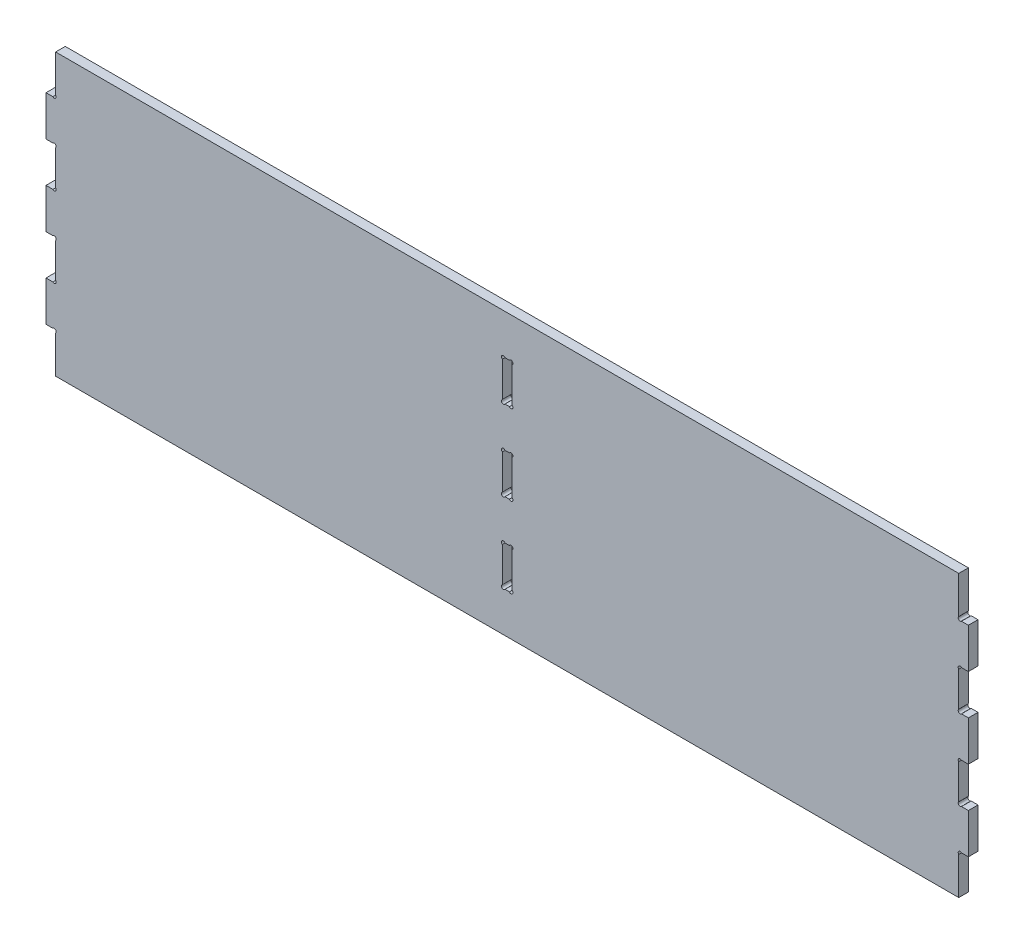
from build123d import *

# Parameters (mm, degrees)
BOSS_EXTRUDE1_DEPTH = 12


with BuildPart() as part:
    # Sketch1 → Boss-Extrude1 (new body)
    with BuildSketch(Plane.XY):
        with BuildLine():
            Line((511.8067094, 188.903885219), (511.8067094, 142.299329353))
            ThreePointArc((511.8067094, 142.299329353), (511.806507744, 138.903885219), (515.20195099, 138.906348311))
            Line((515.20195099, 138.906348311), (523.8067094, 138.906348311))
            Line((523.8067094, 138.906348311), (523.8067094, 138.319810176))
            Line((523.8067094, 138.319810176), (523.8067094, 88.903885219))
            Line((523.8067094, 88.903885219), (518.8067094, 88.903885219))
            Line((518.8067094, 88.903885219), (515.20195099, 88.903885219))
            ThreePointArc((515.20195099, 88.903885219), (511.806507744, 88.906348311), (511.8067094, 85.510904177))
            Line((511.8067094, 85.510904177), (511.8067094, 42.296866261))
            ThreePointArc((511.8067094, 42.296866261), (511.806507744, 38.901422127), (515.20195099, 38.903885219))
            Line((515.20195099, 38.903885219), (518.8067094, 38.903885219))
            Line((518.8067094, 38.903885219), (523.8067094, 38.903885219))
            Line((523.8067094, 38.903885219), (523.8067094, -11.096114781))
            Line((523.8067094, -11.096114781), (518.8067094, -11.096114781))
            Line((518.8067094, -11.096114781), (515.20195099, -11.096114781))
            ThreePointArc((515.20195099, -11.096114781), (511.806507744, -11.093651689), (511.8067094, -14.489095823))
            Line((511.8067094, -14.489095823), (511.8067094, -57.703133739))
            ThreePointArc((511.8067094, -57.703133739), (511.806507744, -61.098577873), (515.20195099, -61.096114781))
            Line((515.20195099, -61.096114781), (518.8067094, -61.096114781))
            Line((518.8067094, -61.096114781), (523.8067094, -61.096114781))
            Line((523.8067094, -61.096114781), (523.8067094, -111.096114781))
            Line((523.8067094, -111.096114781), (518.8067094, -111.096114781))
            Line((518.8067094, -111.096114781), (515.20195099, -111.096114781))
            ThreePointArc((515.20195099, -111.096114781), (511.806507744, -111.093651689), (511.8067094, -114.489095823))
            Line((511.8067094, -114.489095823), (511.8067094, -161.096114781))
            Line((511.8067094, -161.096114781), (-613.922135209, -161.096114781))
            Line((-613.922135209, -161.096114781), (-613.922135209, -114.489095823))
            ThreePointArc((-613.922135209, -114.489095823), (-613.921933554, -111.093651689), (-617.3173768, -111.096114781))
            Line((-617.3173768, -111.096114781), (-620.922135209, -111.096114781))
            Line((-620.922135209, -111.096114781), (-625.922135209, -111.096114781))
            Line((-625.922135209, -111.096114781), (-625.922135209, -61.096114781))
            Line((-625.922135209, -61.096114781), (-620.922135209, -61.096114781))
            Line((-620.922135209, -61.096114781), (-617.3173768, -61.096114781))
            ThreePointArc((-617.3173768, -61.096114781), (-613.921933554, -61.098577873), (-613.922135209, -57.703133739))
            Line((-613.922135209, -57.703133739), (-613.922135209, -14.489095823))
            ThreePointArc((-613.922135209, -14.489095823), (-613.921933554, -11.093651689), (-617.3173768, -11.096114781))
            Line((-617.3173768, -11.096114781), (-620.922135209, -11.096114781))
            Line((-620.922135209, -11.096114781), (-625.922135209, -11.096114781))
            Line((-625.922135209, -11.096114781), (-625.922135209, 38.903885219))
            Line((-625.922135209, 38.903885219), (-620.922135209, 38.903885219))
            Line((-620.922135209, 38.903885219), (-617.3173768, 38.903885219))
            ThreePointArc((-617.3173768, 38.903885219), (-613.921933554, 38.901422127), (-613.922135209, 42.296866261))
            Line((-613.922135209, 42.296866261), (-613.922135209, 85.510904177))
            ThreePointArc((-613.922135209, 85.510904177), (-613.921933554, 88.906348311), (-617.3173768, 88.903885219))
            Line((-617.3173768, 88.903885219), (-620.922135209, 88.903885219))
            Line((-620.922135209, 88.903885219), (-625.922135209, 88.903885219))
            Line((-625.922135209, 88.903885219), (-625.922135209, 138.319810176))
            Line((-625.922135209, 138.319810176), (-625.922135209, 138.906348311))
            Line((-625.922135209, 138.906348311), (-617.3173768, 138.906348311))
            ThreePointArc((-617.3173768, 138.906348311), (-613.921933554, 138.903885219), (-613.922135209, 142.299329353))
            Line((-613.922135209, 142.299329353), (-613.922135209, 188.903885219))
            Line((-613.922135209, 188.903885219), (511.8067094, 188.903885219))
        make_face()
        with BuildLine():
            Line((-48.336173874, 138.906348311), (-53.779251936, 138.906348311))
            ThreePointArc((-53.779251936, 138.906348311), (-57.55476918, 139.403404586), (-57.057712905, 135.627887342))
            Line((-57.057712905, 135.627887342), (-57.057712905, 92.18480928))
            ThreePointArc((-57.057712905, 92.18480928), (-57.55476918, 88.409292036), (-53.779251936, 88.906348311))
            Line((-53.779251936, 88.906348311), (-48.336173874, 88.906348311))
            ThreePointArc((-48.336173874, 88.906348311), (-44.56065663, 88.409292036), (-45.057712905, 92.18480928))
            Line((-45.057712905, 92.18480928), (-45.057712905, 135.627887342))
            ThreePointArc((-45.057712905, 135.627887342), (-44.56065663, 139.403404586), (-48.336173874, 138.906348311))
        make_face(mode=Mode.SUBTRACT)
        with BuildLine():
            Line((-48.345370421, 38.903885219), (-53.770055388, 38.903885219))
            ThreePointArc((-53.770055388, 38.903885219), (-57.548209819, 39.423547352), (-57.057712905, 35.641496003))
            Line((-57.057712905, 35.641496003), (-57.057712905, -7.833725565))
            ThreePointArc((-57.057712905, -7.833725565), (-57.548209819, -11.615776914), (-53.770055388, -11.096114781))
            Line((-53.770055388, -11.096114781), (-48.345370421, -11.096114781))
            ThreePointArc((-48.345370421, -11.096114781), (-44.567215991, -11.615776914), (-45.057712905, -7.833725565))
            Line((-45.057712905, -7.833725565), (-45.057712905, 35.641496003))
            ThreePointArc((-45.057712905, 35.641496003), (-44.567215991, 39.423547352), (-48.345370421, 38.903885219))
        make_face(mode=Mode.SUBTRACT)
        with BuildLine():
            Line((-48.336173874, -61.096114781), (-53.779251936, -61.096114781))
            ThreePointArc((-53.779251936, -61.096114781), (-57.55476918, -60.599058506), (-57.057712905, -64.37457575))
            Line((-57.057712905, -64.37457575), (-57.057712905, -107.817653812))
            ThreePointArc((-57.057712905, -107.817653812), (-57.55476918, -111.593171056), (-53.779251936, -111.096114781))
            Line((-53.779251936, -111.096114781), (-48.336173874, -111.096114781))
            ThreePointArc((-48.336173874, -111.096114781), (-44.56065663, -111.593171056), (-45.057712905, -107.817653812))
            Line((-45.057712905, -107.817653812), (-45.057712905, -64.37457575))
            ThreePointArc((-45.057712905, -64.37457575), (-44.56065663, -60.599058506), (-48.336173874, -61.096114781))
        make_face(mode=Mode.SUBTRACT)
    extrude(amount=BOSS_EXTRUDE1_DEPTH)


solid = part.part
